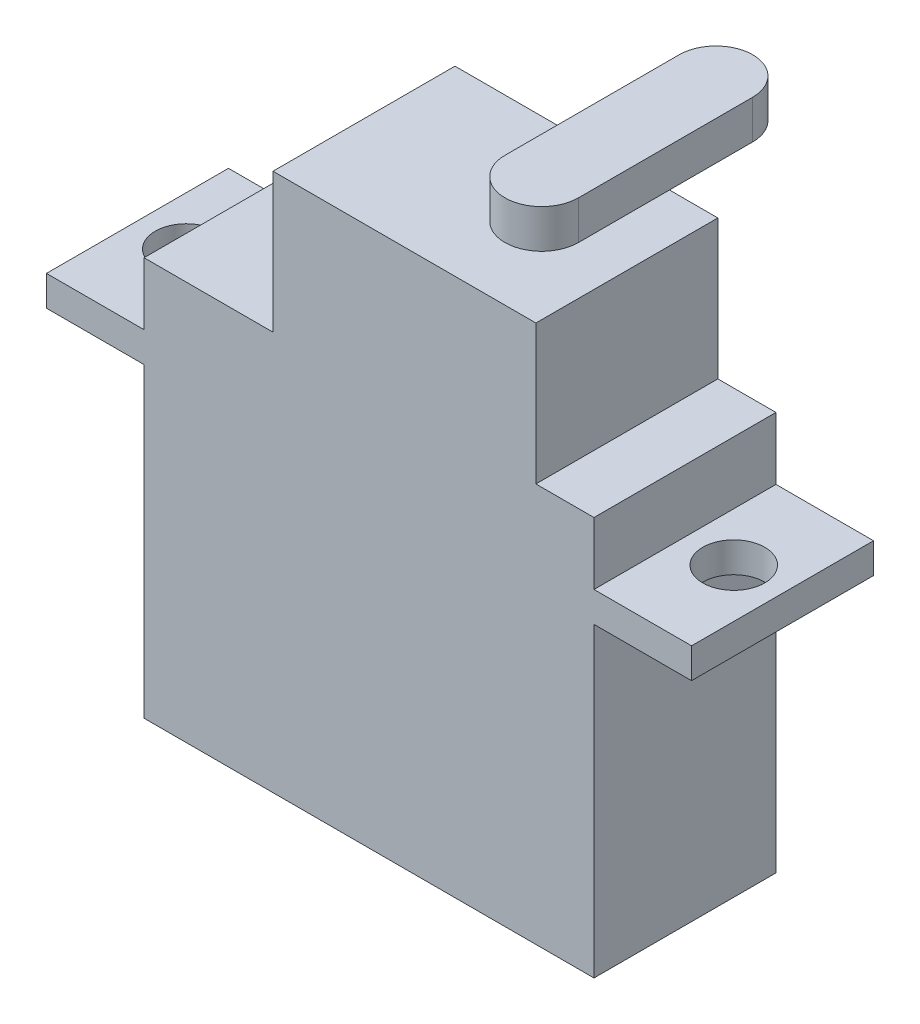
from build123d import *

# Parameters (mm, degrees)
SKETCH3_W           = 29.5148
SKETCH3_H           = 11.938
BOSS_EXTRUDE1_DEPTH = 26.162
SKETCH4_W           = 11.938
SKETCH4_H           = 1.9812
BOSS_EXTRUDE2_DEPTH = 6.4008
SKETCH5_R           = 2.032
CUT_EXTRUDE1_DEPTH  = 6.4008
SKETCH6_W           = 17.2466
SKETCH6_H           = 11.938
BOSS_EXTRUDE3_DEPTH = 9.144
BOSS_EXTRUDE4_DEPTH = 2.54


with BuildPart() as part:
    # Sketch3 → Boss-Extrude1 (new body)
    with BuildSketch(Plane(origin=(0, 0, 0), x_dir=(1, 0, 0), z_dir=(0, 1, 0))):
        with Locations((14.7574, -5.969)):
            Rectangle(SKETCH3_W, SKETCH3_H)
    extrude(amount=BOSS_EXTRUDE1_DEPTH)

    # Sketch4 → Boss-Extrude2 (add)
    with BuildSketch(Plane(origin=(29.5148, 0, 0), x_dir=(0, 0, -1), z_dir=(1, 0, 0))):
        with Locations((-5.969, 21.082)):
            Rectangle(SKETCH4_W, SKETCH4_H)
    boss_extrude2 = extrude(amount=BOSS_EXTRUDE2_DEPTH)

    # Mirror1: Boss-Extrude2 across plane
    add(boss_extrude2.mirror(Plane(origin=(14.7574, 0, 0), x_dir=(0, 0, 1), z_dir=(1, 0, 0))))

    # Sketch5 → Cut-Extrude1 (cut)
    with BuildSketch(Plane(origin=(0, 22.0726, 0), x_dir=(1, 0, 0), z_dir=(0, 1, 0))):
        with Locations((32.7152, -5.969)):
            Circle(SKETCH5_R)
    cut_extrude1 = extrude(amount=-CUT_EXTRUDE1_DEPTH, mode=Mode.SUBTRACT)

    # Mirror2: Cut-Extrude1 across plane
    add(cut_extrude1.mirror(Plane(origin=(14.7574, 0, 0), x_dir=(0, 0, 1), z_dir=(1, 0, 0))), mode=Mode.SUBTRACT)

    # Sketch6 → Boss-Extrude3 (add)
    with BuildSketch(Plane(origin=(0, 26.162, 0), x_dir=(1, 0, 0), z_dir=(0, 1, 0))):
        with Locations((17.0815, -5.969)):
            Rectangle(SKETCH6_W, SKETCH6_H)
    extrude(amount=BOSS_EXTRUDE3_DEPTH)

    # Sketch7 → Boss-Extrude4 (add)
    with BuildSketch(Plane(origin=(0, 35.306, 0), x_dir=(1, 0, 0), z_dir=(0, 1, 0))):
        with BuildLine():
            Line((17.7038, -5.969), (17.7038, 5.461))
            ThreePointArc((17.7038, 5.461), (20.1168, 7.874), (22.5298, 5.461))
            Line((22.5298, 5.461), (22.5298, -5.969))
            ThreePointArc((22.5298, -5.969), (20.1168, -8.382), (17.7038, -5.969))
        make_face()
    extrude(amount=BOSS_EXTRUDE4_DEPTH)


solid = part.part
